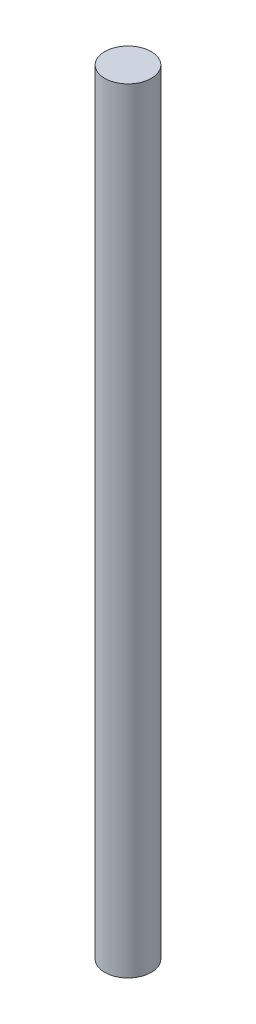
from build123d import *

# Parameters (mm, degrees)
SKETCH2_R           = 7.62
BOSS_EXTRUDE2_DEPTH = 254
SKETCH3_R           = 5.08
CUT_EXTRUDE1_DEPTH  = 8.62


with BuildPart() as part:
    # Sketch2 → Boss-Extrude2 (new body)
    with BuildSketch(Plane(origin=(0, 0, 0), x_dir=(1, 0, 0), z_dir=(0, 1, 0))):
        Circle(SKETCH2_R)
    extrude(amount=BOSS_EXTRUDE2_DEPTH)

    # Sketch3 → Cut-Extrude1 (cut, through all)
    with BuildSketch(Plane(origin=(0, 0, 0), x_dir=(0, 0, -1), z_dir=(1, 0, 0))):
        with Locations((0, 157.537141192)):
            Circle(SKETCH3_R)
        with Locations((0, 81.337141192)):
            Circle(SKETCH3_R)
    extrude(amount=-CUT_EXTRUDE1_DEPTH, mode=Mode.SUBTRACT)


solid = part.part
